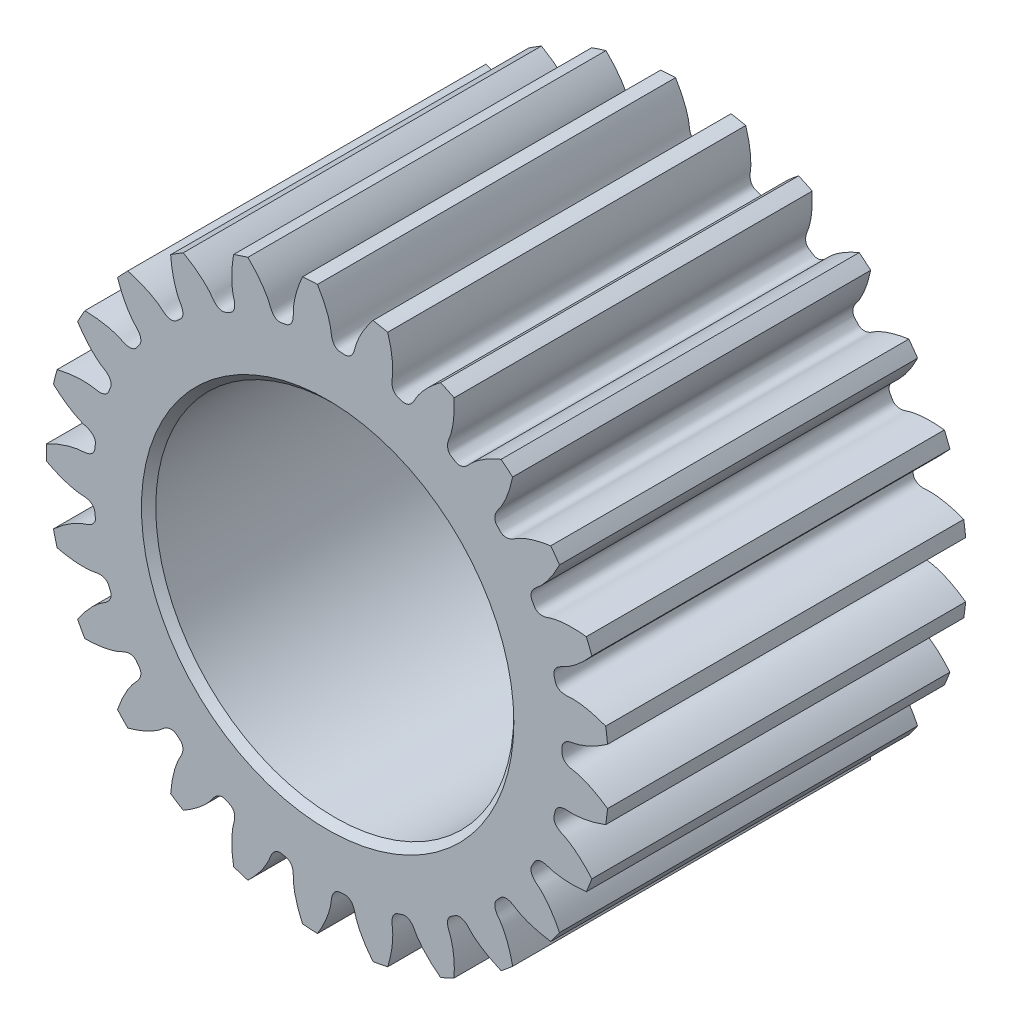
from build123d import *

# Parameters (mm, degrees)
SKETCHREVOLVESUN_FIXED02_W       = 12.7
SKETCHREVOLVESUN_FIXED02_H       = 9.976114349
TOOTHEXTRUDECUTSUN_FIXED02_DEPTH = 6.35
PATTERNSUN_FIXED02_COUNT         = 25


with BuildPart() as part:
    # SketchRevolveSun_Fixed02 → Sun_Fixed02 (revolve)
    with BuildSketch(Plane(origin=(0, 0, 0), x_dir=(0, 0, -1), z_dir=(1, 0, 0))):
        with Locations((0, 4.988057175)):
            Rectangle(SKETCHREVOLVESUN_FIXED02_W, SKETCHREVOLVESUN_FIXED02_H)
    revolve(axis=Axis((0, 0, 0), (0, 0, -1)))

    # SketchToothSun_Fixed02 → ToothExtrudeCutSun_Fixed02 (cut, symmetric)
    with BuildSketch(Plane.XY):
        with BuildLine():
            ThreePointArc((9.961919655, 1.01073529), (10.01306292, 0), (9.961919655, -1.01073529))
            add(Edge.make_bspline(
                [(9.961919655, -1.01073529), (9.854074692, -0.933284365), (9.710198868, -0.838286052), (9.528828185, -0.733761986), (9.430882822, -0.681004809), (9.337876893, -0.634302812), (9.250072387, -0.593325983), (9.167716198, -0.557734102), (9.091039959, -0.527177513), (9.020259499, -0.501298555), (8.955575129, -0.479729132), (8.897169502, -0.462101192), (8.845213203, -0.448016273), (8.799846457, -0.437142082), (8.737807078, -0.423940117), (8.683261745, -0.416666679), (8.635774669, -0.405692461), (8.615560494, -0.400503459), (8.595782592, -0.394828723), (8.576411933, -0.388654739), (8.557418854, -0.381942225), (8.538770162, -0.374646011), (8.520430438, -0.366706795), (8.502362876, -0.358049628), (8.484531253, -0.348579903), (8.466903175, -0.338179314), (8.449455351, -0.326701389), (8.432181766, -0.313967334), (8.415105855, -0.299763349), (8.398297718, -0.283841595), (8.381896861, -0.26592837), (8.366139094, -0.245744575), (8.351382896, -0.223044128), (8.33812375, -0.197674757), (8.326983841, -0.169654989), (8.318644504, -0.139260531), (8.314081116, -0.109059583), (8.312122436, -0.062432083), (8.314403723, 0), (8.312122436, 0.062432083), (8.314081116, 0.109059583), (8.318644504, 0.139260531), (8.326983841, 0.169654989), (8.33812375, 0.197674757), (8.351382896, 0.223044128), (8.366139094, 0.245744575), (8.381896861, 0.26592837), (8.398297718, 0.283841595), (8.415105855, 0.299763349), (8.432181766, 0.313967334), (8.449455351, 0.326701389), (8.466903175, 0.338179314), (8.484531253, 0.348579903), (8.502362876, 0.358049628), (8.520430438, 0.366706795), (8.538770162, 0.374646011), (8.557418854, 0.381942225), (8.576411933, 0.388654739), (8.595782592, 0.394828723), (8.615560494, 0.400503459), (8.635774669, 0.405692461), (8.683261745, 0.416666679), (8.737807078, 0.423940117), (8.799846457, 0.437142082), (8.845213203, 0.448016273), (8.897169502, 0.462101192), (8.955575129, 0.479729132), (9.020259499, 0.501298555), (9.091039959, 0.527177513), (9.167716198, 0.557734102), (9.250072387, 0.593325983), (9.337876893, 0.634302812), (9.430882822, 0.681004809), (9.528828185, 0.733761986), (9.710198868, 0.838286052), (9.854074692, 0.933284365), (9.961919655, 1.01073529)],
                knots=[0, 0, 0, 0, 0.097254541, 0.126170097, 0.153333195, 0.178743836, 0.202402018, 0.224307742, 0.244461009, 0.262861818, 0.279510168, 0.294406061, 0.307549496, 0.318940474, 0.328578993, 0.354007628, 0.35918316, 0.364275529, 0.369295266, 0.374254533, 0.379167399, 0.384050186, 0.388921844, 0.393804391, 0.398723371, 0.403708329, 0.408793208, 0.414016582, 0.419421505, 0.425054685, 0.430964534, 0.437197553, 0.443792505, 0.45077224, 0.45813389, 0.465839744, 0.473812597, 0.480450502, 0.5, 0.519549498, 0.526187403, 0.534160256, 0.54186611, 0.54922776, 0.556207495, 0.562802447, 0.569035466, 0.574945315, 0.580578495, 0.585983418, 0.591206792, 0.596291671, 0.601276629, 0.606195609, 0.611078156, 0.615949814, 0.620832601, 0.625745467, 0.630704734, 0.635724471, 0.64081684, 0.645992372, 0.671421007, 0.681059526, 0.692450504, 0.705593939, 0.720489832, 0.737138182, 0.755538991, 0.775692258, 0.797597982, 0.821256164, 0.846666805, 0.873829903, 0.902745459, 1, 1, 1, 1], degree=3))
        make_face()
    toothextrudecutsun_fixed02 = extrude(amount=TOOTHEXTRUDECUTSUN_FIXED02_DEPTH, both=True, mode=Mode.SUBTRACT)

    # PatternSun_Fixed02: ToothExtrudeCutSun_Fixed02 ×25 about axis
    patternsun_fixed02_axis = Axis((0, 0, 55), (0, 0, -1))
    for i in range(1, PATTERNSUN_FIXED02_COUNT):
        add(toothextrudecutsun_fixed02.rotate(patternsun_fixed02_axis, i * 360 / PATTERNSUN_FIXED02_COUNT), mode=Mode.SUBTRACT)

    # BoreRevolveSketch → BoreRevolveCut (revolve, cut)
    with BuildSketch(Plane(origin=(0, 0, 0), x_dir=(0, 0, -1), z_dir=(1, 0, 0))):
        Polygon((-6.35, 0), (6.35, 0), (6.35, 6.604), (6.096, 6.35), (-6.096, 6.35), (-6.35, 6.604), align=None)
    revolve(axis=Axis((0, 0, 0), (0, 0, -1)), mode=Mode.SUBTRACT)


solid = part.part
